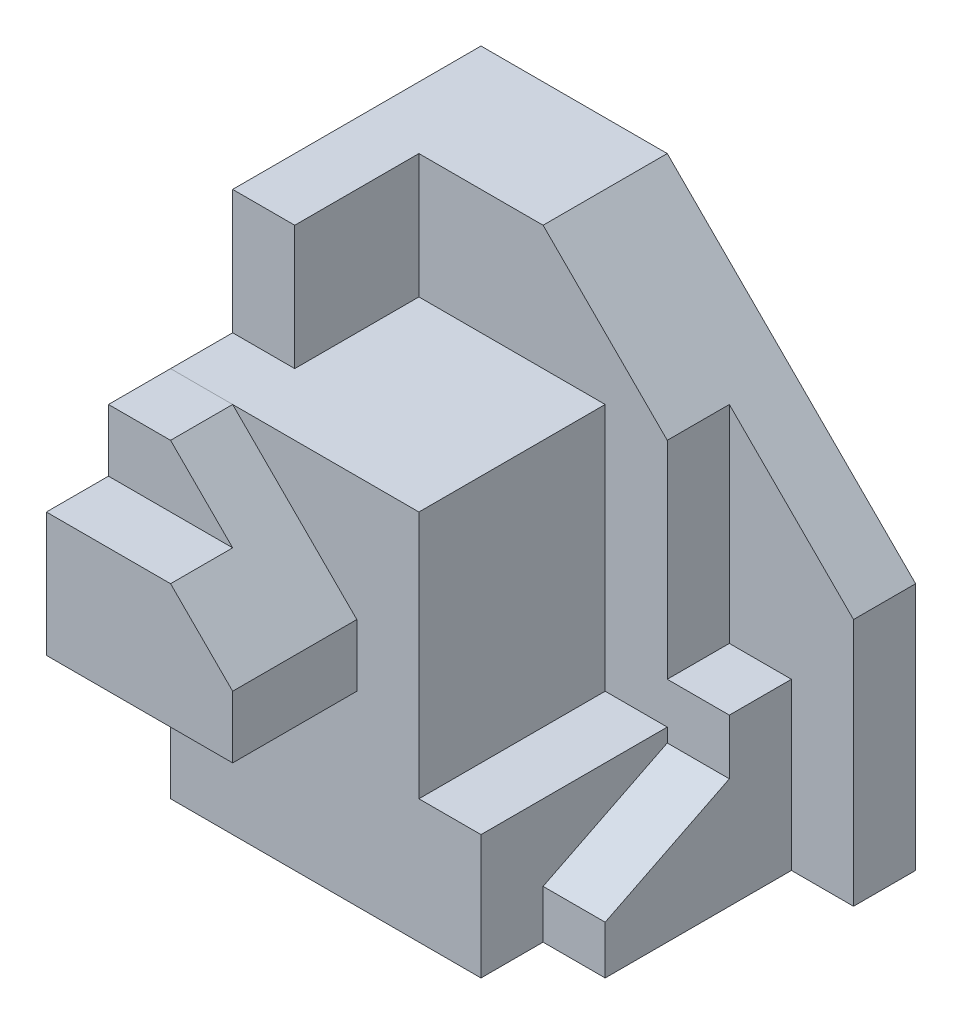
from build123d import *

# Parameters (mm, degrees)
SKETCH1_W           = 50
SKETCH1_H           = 50
BOSS_EXTRUDE1_DEPTH = 60
SKETCH2_W           = 10
SKETCH2_H           = 30
CUT_EXTRUDE1_DEPTH  = 40
SKETCH3_W           = 30
SKETCH3_H           = 20
BOSS_EXTRUDE2_DEPTH = 30
CHAMFER1_SIZE       = 20
SKETCH4_W           = 10
SKETCH4_H           = 10
CUT_EXTRUDE2_DEPTH  = 40
SKETCH6_W           = 10
SKETCH6_H           = 80
BOSS_EXTRUDE3_DEPTH = 20
BOSS_EXTRUDE4_DEPTH = 20
CHAMFER2_SIZE       = 40
BOSS_EXTRUDE5_DEPTH = 10


with BuildPart() as part:
    # Sketch1 → Boss-Extrude1 (new body)
    with BuildSketch(Plane(origin=(0, 0, 0), x_dir=(1, 0, 0), z_dir=(0, 1, 0))):
        Rectangle(SKETCH1_W, SKETCH1_H)
    extrude(amount=BOSS_EXTRUDE1_DEPTH)

    # Sketch2 → Cut-Extrude1 (cut)
    with BuildSketch(Plane(origin=(0, 60, 0), x_dir=(1, 0, 0), z_dir=(0, 1, 0))):
        with Locations((20, -10)):
            Rectangle(SKETCH2_W, SKETCH2_H)
    extrude(amount=-CUT_EXTRUDE1_DEPTH, mode=Mode.SUBTRACT)

    # Sketch6 → Boss-Extrude3 (add)
    with BuildSketch(Plane(origin=(25, 0, 0), x_dir=(0, 0, -1), z_dir=(1, 0, 0))):
        with Locations((20, 40)):
            Rectangle(SKETCH6_W, SKETCH6_H)
    extrude(amount=BOSS_EXTRUDE3_DEPTH)

    # Sketch7 → Boss-Extrude4 (add)
    with BuildSketch(Plane(origin=(0, 60, 0), x_dir=(1, 0, 0), z_dir=(0, 1, 0))):
        Polygon((-25, -15), (-15, -15), (-15, 5), (25, 5), (25, 15), (25, 25), (-25, 25), align=None)
    extrude(amount=BOSS_EXTRUDE4_DEPTH)

    # Chamfer2
    chamfer2_edges = [part.edges().sort_by_distance(p)[0] for p in [
        (45, 80, -20),
    ]]
    chamfer(chamfer2_edges, length=CHAMFER2_SIZE)

    # Sketch8 → Boss-Extrude5 (add)
    with BuildSketch(Plane(origin=(25, 0, 0), x_dir=(0, 0, -1), z_dir=(1, 0, 0))):
        Polygon((15, 26.66931211), (15, 0), (-15, 0), (-15, 7.782203516), (5, 17.782203516), (5, 26.66931211), align=None)
    extrude(amount=BOSS_EXTRUDE5_DEPTH)


with BuildPart() as body_2:
    # Sketch3 → Boss-Extrude2 (new body)
    with BuildSketch(Plane(origin=(0, 60, 0), x_dir=(1, 0, 0), z_dir=(0, 1, 0))):
        with Locations((-10, -35)):
            Rectangle(SKETCH3_W, SKETCH3_H)
    extrude(amount=-BOSS_EXTRUDE2_DEPTH)

    # Chamfer1
    chamfer1_edges = [body_2.edges().sort_by_distance(p)[0] for p in [
        (5, 60, 35),
    ]]
    chamfer(chamfer1_edges, length=CHAMFER1_SIZE)

    # Sketch4 → Cut-Extrude2 (cut)
    with BuildSketch(Plane.ZY.offset(25)):
        with Locations((40, 55)):
            Rectangle(SKETCH4_W, SKETCH4_H)
    extrude(amount=-CUT_EXTRUDE2_DEPTH, mode=Mode.SUBTRACT)


solid = Compound([part.part, body_2.part])
